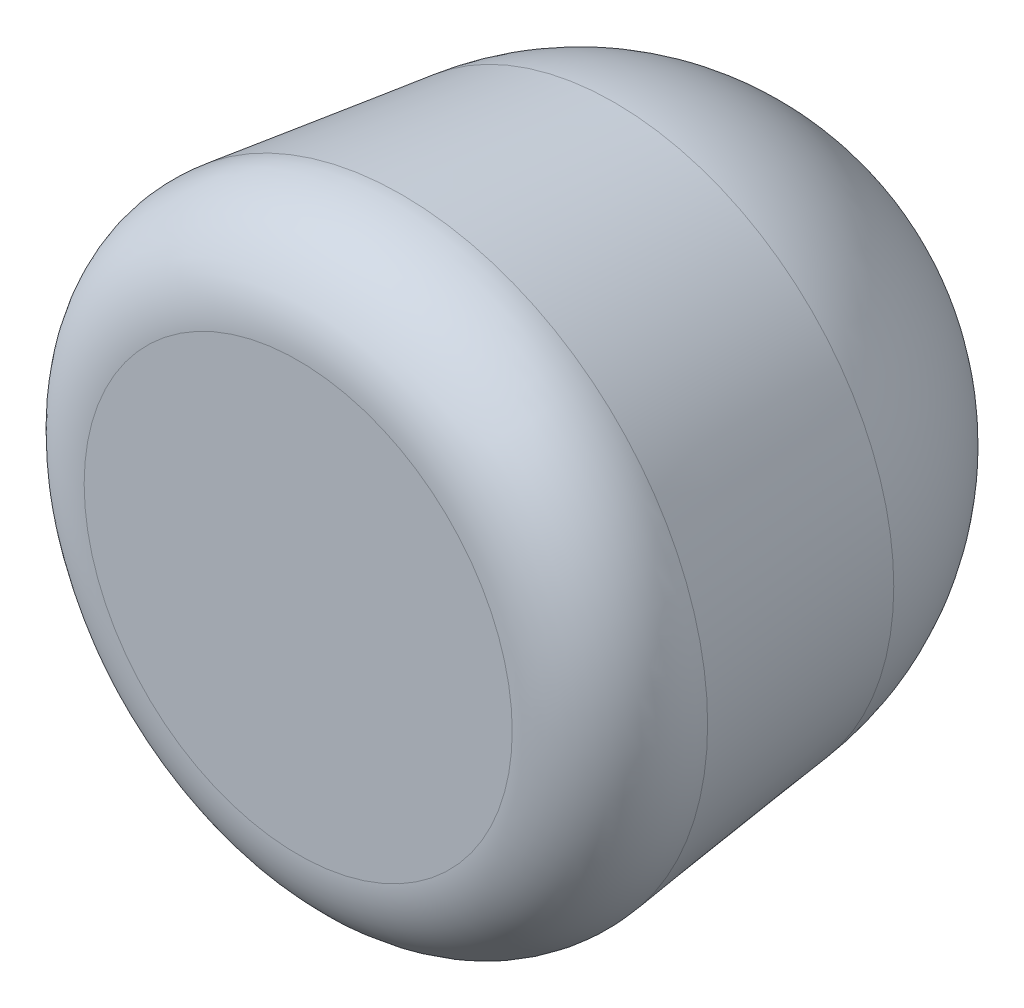
from build123d import *


with BuildPart() as part:
    # Sketch1 → Revolve1 (revolve)
    with BuildSketch(Plane(origin=(0, 0, 0), x_dir=(0, 0, -1), z_dir=(1, 0, 0))):
        with BuildLine():
            add(Edge.make_bspline(
                [(18.697578281, 151.248671288), (9.384236453, 152.4), (0, 152.4), (-152.4, 152.4), (-152.4, 0)],
                knots=[6.149799155, 6.149799155, 6.149799155, 6.283185307, 6.283185307, 7.853981634, 7.853981634, 7.853981634], degree=2, weights=[0.954481178, 0.975128603, 1, 0.707106781, 1]))
            Line((18.697578281, 151.248671288), (-96.265623923, 165.460587693))
            ThreePointArc((-96.265623923, 165.460587693), (-135.515564288, 153.299759076), (-152.4, 115.83832021))
            Line((-152.4, 115.83832021), (-152.4, 0))
        make_face()
        with BuildLine():
            Line((152.4, 0), (-152.4, 0))
            add(Edge.make_bspline(
                [(152.4, 0), (152.4, 152.4), (0, 152.4), (-152.4, 152.4), (-152.4, 0)],
                knots=[4.71238898, 4.71238898, 4.71238898, 6.283185307, 6.283185307, 7.853981634, 7.853981634, 7.853981634], degree=2, weights=[1, 0.707106781, 1, 0.707106781, 1]))
        make_face()
    revolve(axis=Axis((0, 0, 0), (0, 0, -1)))


solid = part.part
